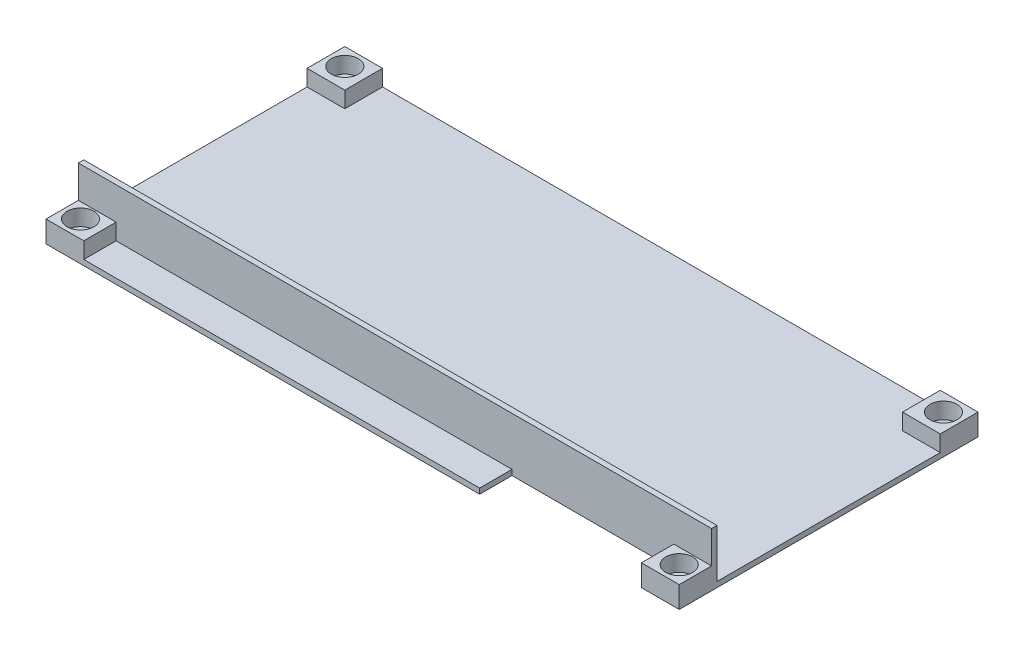
from build123d import *

# Parameters (mm, degrees)
SKETCH1_W           = 117.4
SKETCH1_H           = 55.4
BOSS_EXTRUDE1_DEPTH = 1
SKETCH2_W           = 7
SKETCH2_H           = 7
BOSS_EXTRUDE2_DEPTH = 3
SKETCH3_R           = 1.35
CUT_EXTRUDE1_DEPTH  = 5
SKETCH7_W           = 30
SKETCH7_H           = 6
CUT_EXTRUDE5_DEPTH  = 5
SKETCH9_R           = 2.5
CUT_EXTRUDE6_DEPTH  = 3
SKETCH10_W          = 117.4
SKETCH10_H          = 1
BOSS_EXTRUDE3_DEPTH = 9


with BuildPart() as part:
    # Sketch1 → Boss-Extrude1 (new body)
    with BuildSketch(Plane(origin=(0, 0, 0), x_dir=(1, 0, 0), z_dir=(0, 1, 0))):
        Rectangle(SKETCH1_W, SKETCH1_H)
    extrude(amount=BOSS_EXTRUDE1_DEPTH)

    # Sketch2 → Boss-Extrude2 (add)
    with BuildSketch(Plane(origin=(0, 1, 0), x_dir=(1, 0, 0), z_dir=(0, 1, 0))):
        with Locations((55.2, 24.2)):
            Rectangle(SKETCH2_W, SKETCH2_H)
        with Locations((-55.2, 24.2)):
            Rectangle(SKETCH2_W, SKETCH2_H)
        with Locations((55.2, -24.2)):
            Rectangle(SKETCH2_W, SKETCH2_H)
        with Locations((-55.2, -24.2)):
            Rectangle(SKETCH2_W, SKETCH2_H)
    extrude(amount=BOSS_EXTRUDE2_DEPTH)

    # Sketch3 → Cut-Extrude1 (cut, through all)
    with BuildSketch(Plane(origin=(0, 4, 0), x_dir=(1, 0, 0), z_dir=(0, 1, 0))):
        with Locations((-55.5, 24.5)):
            Circle(SKETCH3_R)
        with Locations((55.5, 24.5)):
            Circle(SKETCH3_R)
        with Locations((55.5, -24.5)):
            Circle(SKETCH3_R)
        with Locations((-55.5, -24.5)):
            Circle(SKETCH3_R)
    extrude(amount=-CUT_EXTRUDE1_DEPTH, mode=Mode.SUBTRACT)

    # Sketch7 → Cut-Extrude5 (cut, through all)
    with BuildSketch(Plane.XZ):
        with Locations((36.7, 24.7)):
            Rectangle(SKETCH7_W, SKETCH7_H)
    extrude(amount=-CUT_EXTRUDE5_DEPTH, mode=Mode.SUBTRACT)

    # Sketch9 → Cut-Extrude6 (cut)
    with BuildSketch(Plane(origin=(0, 4, 0), x_dir=(1, 0, 0), z_dir=(0, 1, 0))):
        with Locations((-55.5, 24.5)):
            Circle(SKETCH9_R)
        with Locations((55.5, 24.5)):
            Circle(SKETCH9_R)
        with Locations((55.5, -24.5)):
            Circle(SKETCH9_R)
        with Locations((-55.5, -24.5)):
            Circle(SKETCH9_R)
    extrude(amount=-CUT_EXTRUDE6_DEPTH, mode=Mode.SUBTRACT)

    # Sketch10 → Boss-Extrude3 (add)
    with BuildSketch(Plane(origin=(0, 1, 0), x_dir=(1, 0, 0), z_dir=(0, 1, 0))):
        with Locations((0, -21.2)):
            Rectangle(SKETCH10_W, SKETCH10_H)
    extrude(amount=BOSS_EXTRUDE3_DEPTH)


solid = part.part
